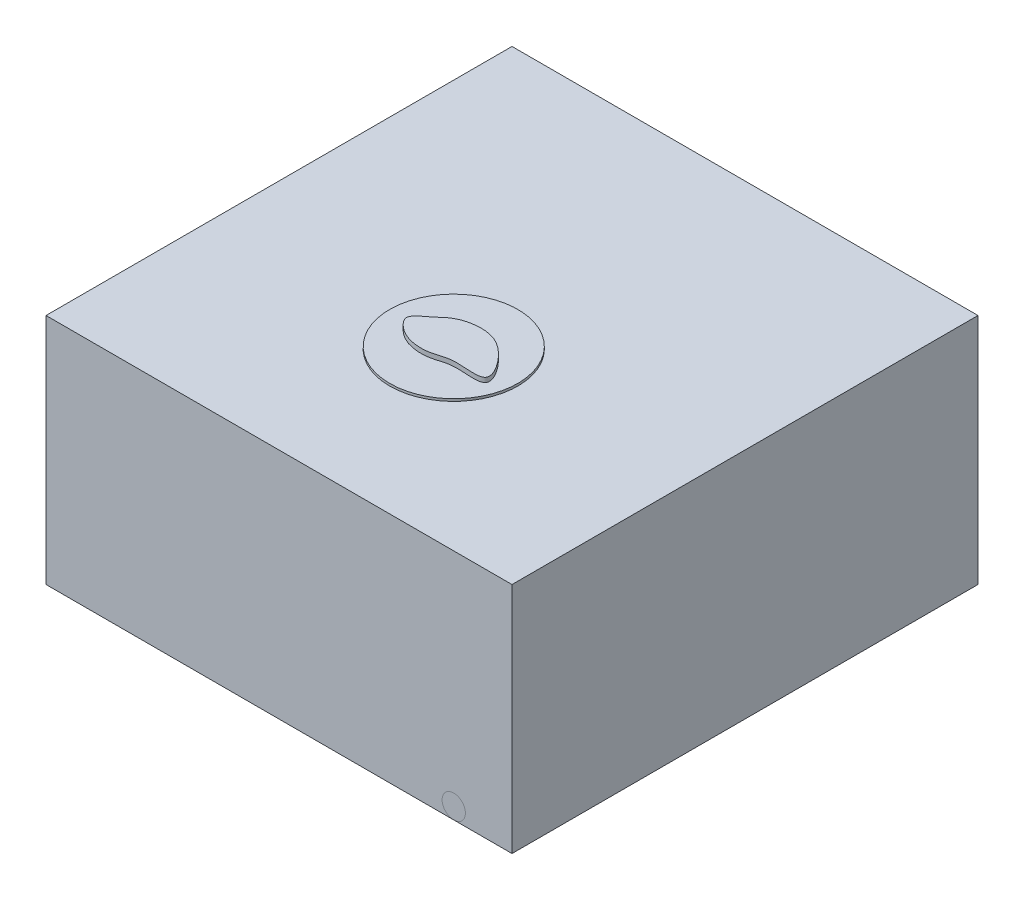
from build123d import *

# Parameters (mm, degrees)
SKETCH1_W             = 20
SKETCH1_H             = 10
BOSS_EXTRUDE1_DEPTH   = 20
SKETCH2_R             = 0.5
SKETCH5_R             = 2.75
BOSS_EXTRUDE4_DEPTH   = 0.1
SKETCH8_R             = 0.005
BOSS_EXTRUDE5_DEPTH   = 0.1
BOSS_EXTRUDE5_2_DEPTH = 0.1
BOSS_EXTRUDE5_3_DEPTH = 0.1
BOSS_EXTRUDE5_4_DEPTH = 0.1
BOSS_EXTRUDE5_5_DEPTH = 0.1
BOSS_EXTRUDE5_6_DEPTH = 0.1
BOSS_EXTRUDE5_7_DEPTH = 0.1
BOSS_EXTRUDE5_8_DEPTH = 0.1
BOSS_EXTRUDE5_9_DEPTH = 0.1
SLICE_2_DEPTH         = 0.3


with BuildPart() as part:
    # Sketch1 → Boss-Extrude1 (new body)
    with BuildSketch(Plane.XY):
        Rectangle(SKETCH1_W, SKETCH1_H)
    extrude(amount=BOSS_EXTRUDE1_DEPTH)


with BuildPart() as body_2:
    # ag/agcl electrodes: sweep along a path in Sketch3
    with BuildLine(Plane(origin=(7.5, 0, 0), x_dir=(0, 0, -1), z_dir=(1, 0, 0))) as ag_agcl_electrodes_path:
        Line((-20, -4.5), (-5, -4.5))
        ThreePointArc((-5, -4.5), (-4.292893219, -4.207106781), (-4, -3.5))
        Line((-4, -3.5), (-4, 5))
    # Sketch2 → ag/agcl electrodes (sweep)
    with BuildSketch(Plane.XY.offset(20)):
        with Locations((-7.5, -4.5)):
            Circle(SKETCH2_R)
        with Locations((7.5, -4.5)):
            Circle(SKETCH2_R)
    sweep(path=ag_agcl_electrodes_path.line)


with BuildPart() as body_3:
    # Sketch5 → Boss-Extrude4 (new body)
    with BuildSketch(Plane(origin=(0, 5, 0), x_dir=(1, 0, 0), z_dir=(0, 1, 0))):
        with Locations(Location((0, -12.5, 0), (0, 0, 270))):
            Circle(SKETCH5_R)
    extrude(amount=BOSS_EXTRUDE4_DEPTH)


with BuildPart() as body_4:
    # Sketch8 → Boss-Extrude5 (new body)
    with BuildSketch(Plane(origin=(0, 5.1, 0), x_dir=(-1, 0, 0), z_dir=(0, -1, 0))):
        with Locations(Location((0, -12.5, 0), (0, 0, 90))):
            Circle(SKETCH8_R)
    extrude(amount=BOSS_EXTRUDE5_DEPTH)


with BuildPart() as body_5:
    # Sketch8 → Boss-Extrude5 2 (new body)
    with BuildSketch(Plane(origin=(0, 5.1, 0), x_dir=(-1, 0, 0), z_dir=(0, -1, 0))):
        with Locations(Location((0.5, -12.5, 0), (0, 0, 90))):
            Circle(SKETCH8_R)
    extrude(amount=BOSS_EXTRUDE5_2_DEPTH)


with BuildPart() as body_6:
    # Sketch8 → Boss-Extrude5 3 (new body)
    with BuildSketch(Plane(origin=(0, 5.1, 0), x_dir=(-1, 0, 0), z_dir=(0, -1, 0))):
        with Locations(Location((0.5, -12, 0), (0, 0, 90))):
            Circle(SKETCH8_R)
    extrude(amount=BOSS_EXTRUDE5_3_DEPTH)


with BuildPart() as body_7:
    # Sketch8 → Boss-Extrude5 4 (new body)
    with BuildSketch(Plane(origin=(0, 5.1, 0), x_dir=(-1, 0, 0), z_dir=(0, -1, 0))):
        with Locations(Location((0, -12, 0), (0, 0, 90))):
            Circle(SKETCH8_R)
    extrude(amount=BOSS_EXTRUDE5_4_DEPTH)


with BuildPart() as body_8:
    # Sketch8 → Boss-Extrude5 5 (new body)
    with BuildSketch(Plane(origin=(0, 5.1, 0), x_dir=(-1, 0, 0), z_dir=(0, -1, 0))):
        with Locations(Location((0.5, -13, 0), (0, 0, 270))):
            Circle(SKETCH8_R)
    extrude(amount=BOSS_EXTRUDE5_5_DEPTH)


with BuildPart() as body_9:
    # Sketch8 → Boss-Extrude5 6 (new body)
    with BuildSketch(Plane(origin=(0, 5.1, 0), x_dir=(-1, 0, 0), z_dir=(0, -1, 0))):
        with Locations(Location((0, -13, 0), (0, 0, 270))):
            Circle(SKETCH8_R)
    extrude(amount=BOSS_EXTRUDE5_6_DEPTH)


with BuildPart() as body_10:
    # Sketch8 → Boss-Extrude5 7 (new body)
    with BuildSketch(Plane(origin=(0, 5.1, 0), x_dir=(-1, 0, 0), z_dir=(0, -1, 0))):
        with Locations(Location((-0.5, -13, 0), (0, 0, 90))):
            Circle(SKETCH8_R)
    extrude(amount=BOSS_EXTRUDE5_7_DEPTH)


with BuildPart() as body_11:
    # Sketch8 → Boss-Extrude5 8 (new body)
    with BuildSketch(Plane(origin=(0, 5.1, 0), x_dir=(-1, 0, 0), z_dir=(0, -1, 0))):
        with Locations(Location((-0.5, -12, 0), (0, 0, 270))):
            Circle(SKETCH8_R)
    extrude(amount=BOSS_EXTRUDE5_8_DEPTH)


with BuildPart() as body_12:
    # Sketch8 → Boss-Extrude5 9 (new body)
    with BuildSketch(Plane(origin=(0, 5.1, 0), x_dir=(-1, 0, 0), z_dir=(0, -1, 0))):
        with Locations(Location((-0.5, -12.5, 0), (0, 0, 270))):
            Circle(SKETCH8_R)
    extrude(amount=BOSS_EXTRUDE5_9_DEPTH)


with BuildPart() as body_13:
    # Sketch4 → slice 2 (new body)
    with BuildSketch(Plane(origin=(0, 5, 0), x_dir=(1, 0, 0), z_dir=(0, 1, 0))):
        with BuildLine():
            add(Edge.make_bspline(
                [(-1.329786825, -12.04709664), (-1.196342031, -11.939424685), (-0.824147777, -11.548957834), (0.251281573, -11.322574475), (1.372606671, -11.746573561), (2.652909809, -13.571837262), (0.780549472, -13.104467787), (-0.122057097, -13.506347246), (-0.994791107, -13.460960152), (-1.586432094, -13.116889112), (-2.086144249, -12.539169772), (-1.569499382, -12.240512354), (-1.329786825, -12.04709664)],
                knots=[0, 0, 0, 0, 0.049562645, 0.182817887, 0.303261475, 0.461561344, 0.613381106, 0.684437877, 0.79516613, 0.866564728, 0.910968514, 1, 1, 1, 1], degree=3))
        make_face()
    extrude(amount=SLICE_2_DEPTH)


solid = Compound([part.part, body_2.part, body_3.part, body_4.part, body_5.part, body_6.part, body_7.part, body_8.part, body_9.part, body_10.part, body_11.part, body_12.part, body_13.part])
